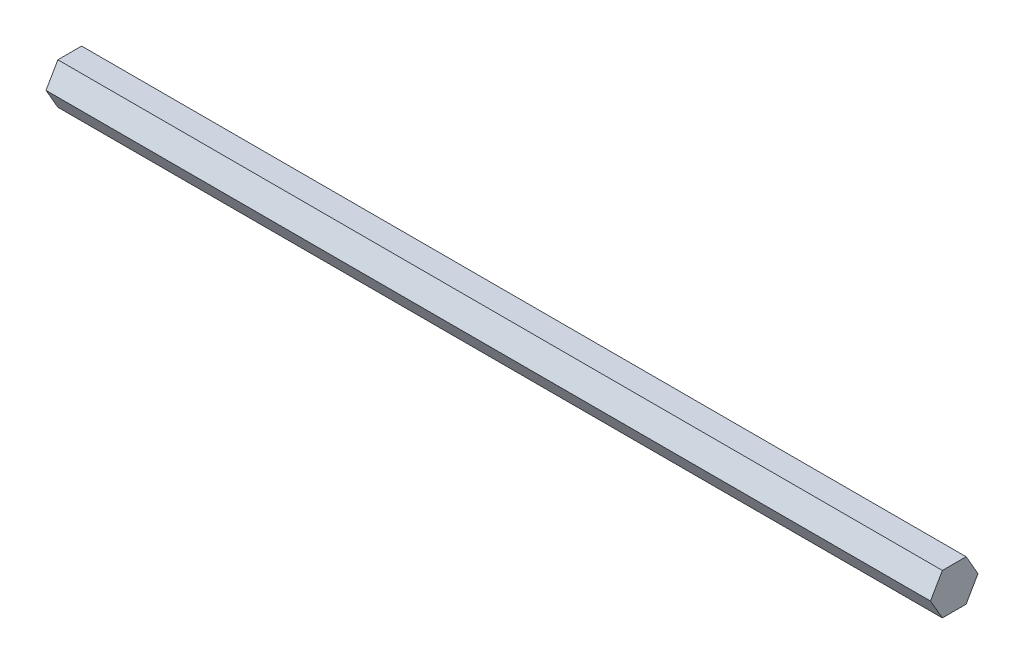
from build123d import *

# Parameters (mm, degrees)
BOSS_EXTRUDE1_DEPTH = 273.05


with BuildPart() as part:
    # Sketch1 → Boss-Extrude1 (new body)
    with BuildSketch(Plane(origin=(0, 0, 0), x_dir=(0, 0, -1), z_dir=(1, 0, 0))):
        Polygon((7.332348419, 0), (3.666174209, 6.35), (-3.666174209, 6.35), (-7.332348419, 0), (-3.666174209, -6.35), (3.666174209, -6.35), align=None)
    extrude(amount=BOSS_EXTRUDE1_DEPTH)


solid = part.part
